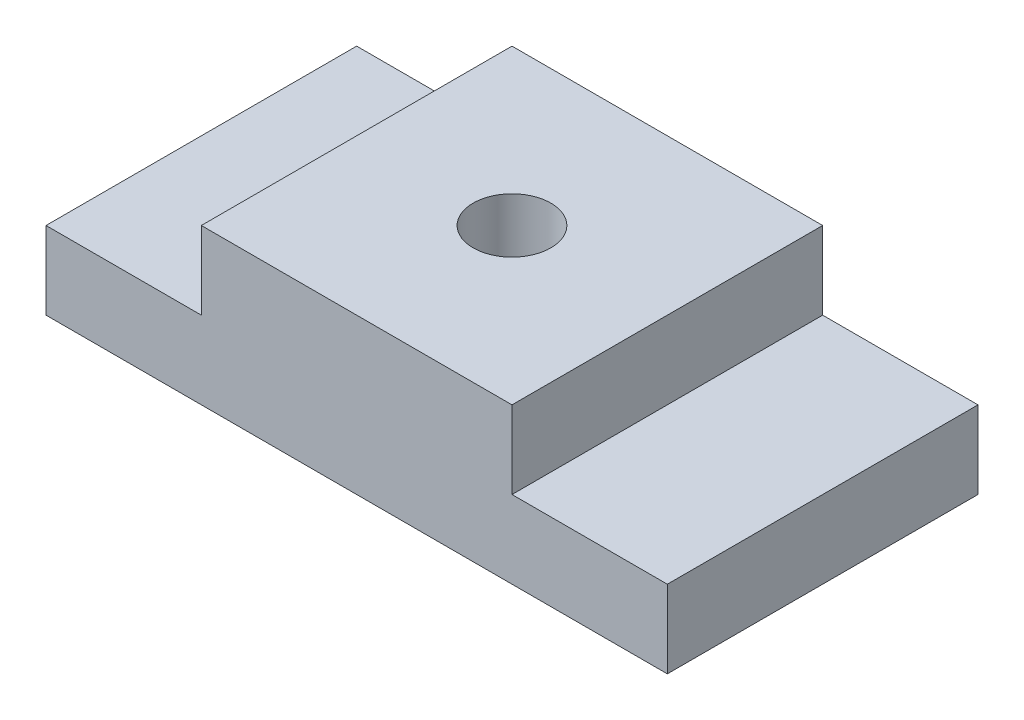
from build123d import *

# Parameters (mm, degrees)
SKETCH1_W           = 80
SKETCH1_H           = 40
BOSS_EXTRUDE1_DEPTH = 10
SKETCH2_W           = 40
SKETCH2_H           = 40
BOSS_EXTRUDE2_DEPTH = 10
SKETCH3_R           = 5
CUT_EXTRUDE1_DEPTH  = 10


with BuildPart() as part:
    # Sketch1 → Boss-Extrude1 (new body)
    with BuildSketch(Plane(origin=(0, 0, 0), x_dir=(1, 0, 0), z_dir=(0, 1, 0))):
        Rectangle(SKETCH1_W, SKETCH1_H)
    extrude(amount=BOSS_EXTRUDE1_DEPTH)

    # Sketch2 → Boss-Extrude2 (add)
    with BuildSketch(Plane(origin=(0, 10, 0), x_dir=(1, 0, 0), z_dir=(0, 1, 0))):
        Rectangle(SKETCH2_W, SKETCH2_H)
    extrude(amount=BOSS_EXTRUDE2_DEPTH)

    # Sketch3 → Cut-Extrude1 (cut)
    with BuildSketch(Plane(origin=(0, 20, 0), x_dir=(1, 0, 0), z_dir=(0, 1, 0))):
        Circle(SKETCH3_R)
    extrude(amount=-CUT_EXTRUDE1_DEPTH, mode=Mode.SUBTRACT)


solid = part.part
